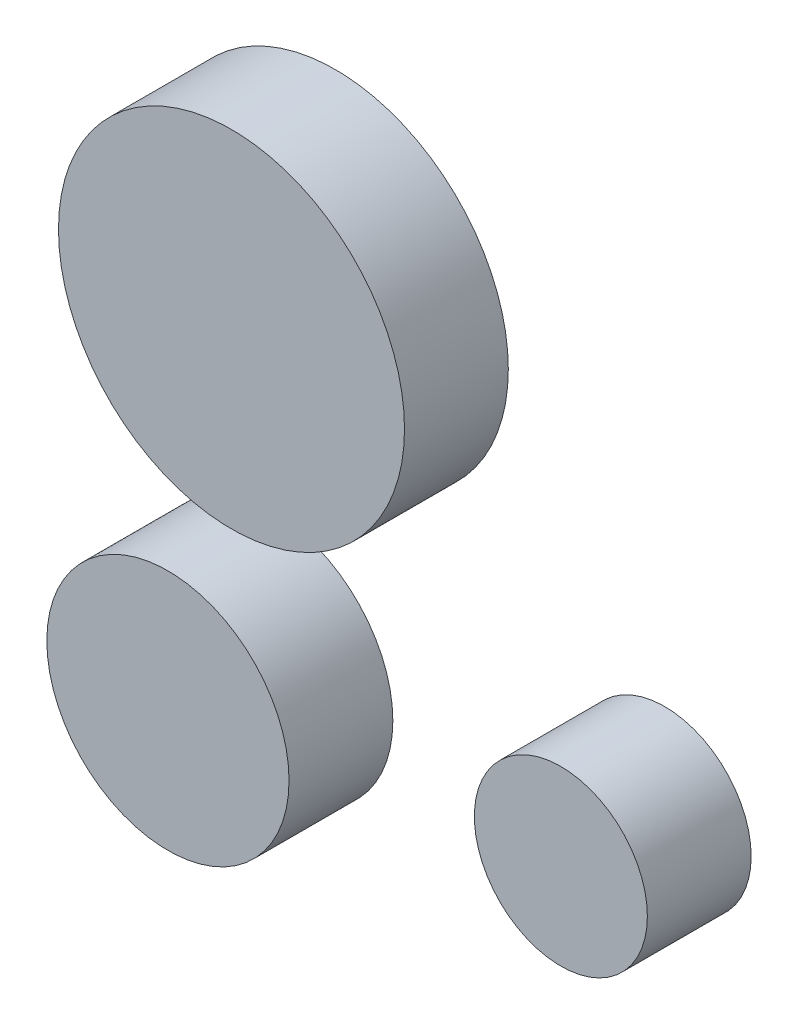
from build123d import *

# Parameters (mm, degrees)
SKETCH1_R             = 12.7
BOSS_EXTRUDE1_DEPTH   = 7.62
SKETCH1_R_2           = 6.35
BOSS_EXTRUDE1_2_DEPTH = 7.62
SKETCH1_R_3           = 8.89
BOSS_EXTRUDE1_3_DEPTH = 7.62


with BuildPart() as part:
    # Sketch1 → Boss-Extrude1 (new body)
    with BuildSketch(Plane.XY):
        Circle(SKETCH1_R)
    extrude(amount=BOSS_EXTRUDE1_DEPTH)


with BuildPart() as body_2:
    # Sketch1 → Boss-Extrude1 2 (new body)
    with BuildSketch(Plane.XY):
        with Locations((24.176307654, -22.055578912)):
            Circle(SKETCH1_R_2)
    extrude(amount=BOSS_EXTRUDE1_2_DEPTH)


with BuildPart() as body_3:
    # Sketch1 → Boss-Extrude1 3 (new body)
    with BuildSketch(Plane.XY):
        with Locations((-4.665603231, -26.579800228)):
            Circle(SKETCH1_R_3)
    extrude(amount=BOSS_EXTRUDE1_3_DEPTH)


solid = Compound([part.part, body_2.part, body_3.part])
